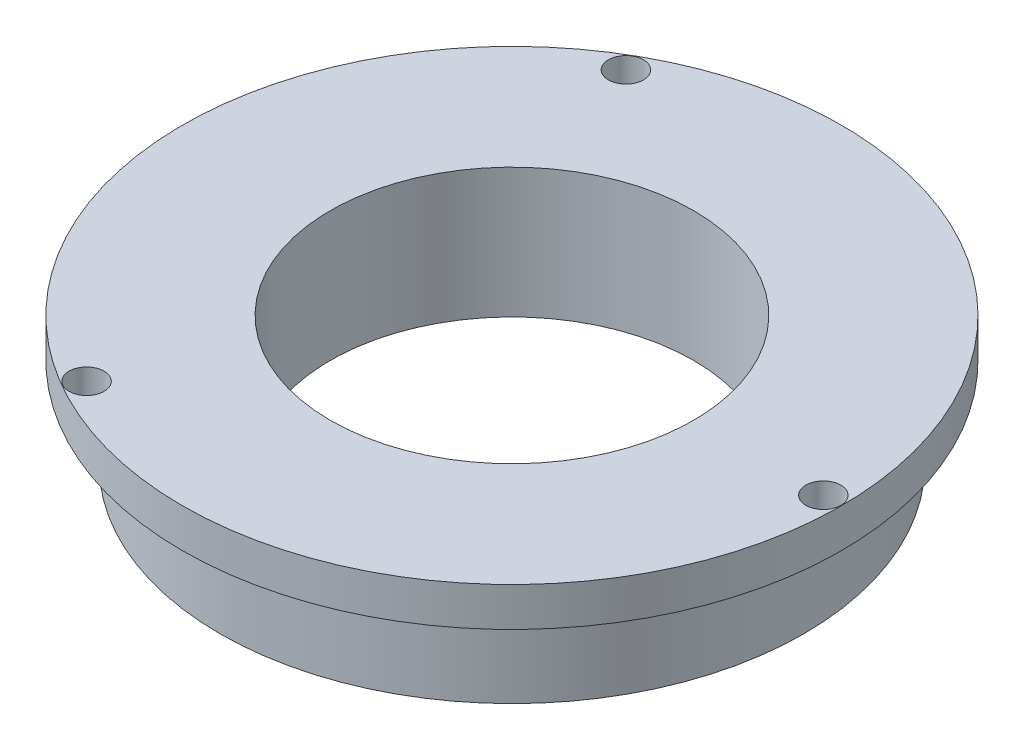
from build123d import *

# Parameters (mm, degrees)
CROQUIS1_R              = 25.4
SALIENTE_EXTRUIR2_DEPTH = 10
CROQUIS4_R              = 14
CORTAR_EXTRUIR2_DEPTH   = 47
CROQUIS5_R              = 25.4
CROQUIS5_R_2            = 22.5
CORTAR_EXTRUIR4_DEPTH   = 7
CROQUIS6_R              = 1.35
CORTAR_EXTRUIR5_DEPTH   = 37


with BuildPart() as part:
    # Croquis1 → Saliente-Extruir2 (new body)
    with BuildSketch(Plane(origin=(0, 0, 0), x_dir=(1, 0, 0), z_dir=(0, 1, 0))):
        Circle(CROQUIS1_R)
    extrude(amount=SALIENTE_EXTRUIR2_DEPTH)

    # Croquis4 → Cortar-Extruir2 (cut)
    with BuildSketch(Plane(origin=(0, 0, 0), x_dir=(1, 0, 0), z_dir=(0, 1, 0))):
        Circle(CROQUIS4_R)
    extrude(amount=CORTAR_EXTRUIR2_DEPTH, mode=Mode.SUBTRACT)

    # Croquis5 → Cortar-Extruir4 (cut)
    with BuildSketch(Plane(origin=(0, 0, 0), x_dir=(1, 0, 0), z_dir=(0, 1, 0))):
        Circle(CROQUIS5_R)
        Circle(CROQUIS5_R_2, mode=Mode.SUBTRACT)
    extrude(amount=CORTAR_EXTRUIR4_DEPTH, mode=Mode.SUBTRACT)

    # Croquis6 → Cortar-Extruir5 (cut)
    with BuildSketch(Plane(origin=(0, 0, 0), x_dir=(1, 0, 0), z_dir=(0, 1, 0))):
        with Locations((24, 0)):
            Circle(CROQUIS6_R)
        with Locations((-12, -20.784609691)):
            Circle(CROQUIS6_R)
        with Locations((-12, 20.784609691)):
            Circle(CROQUIS6_R)
    extrude(amount=CORTAR_EXTRUIR5_DEPTH, mode=Mode.SUBTRACT)


solid = part.part
